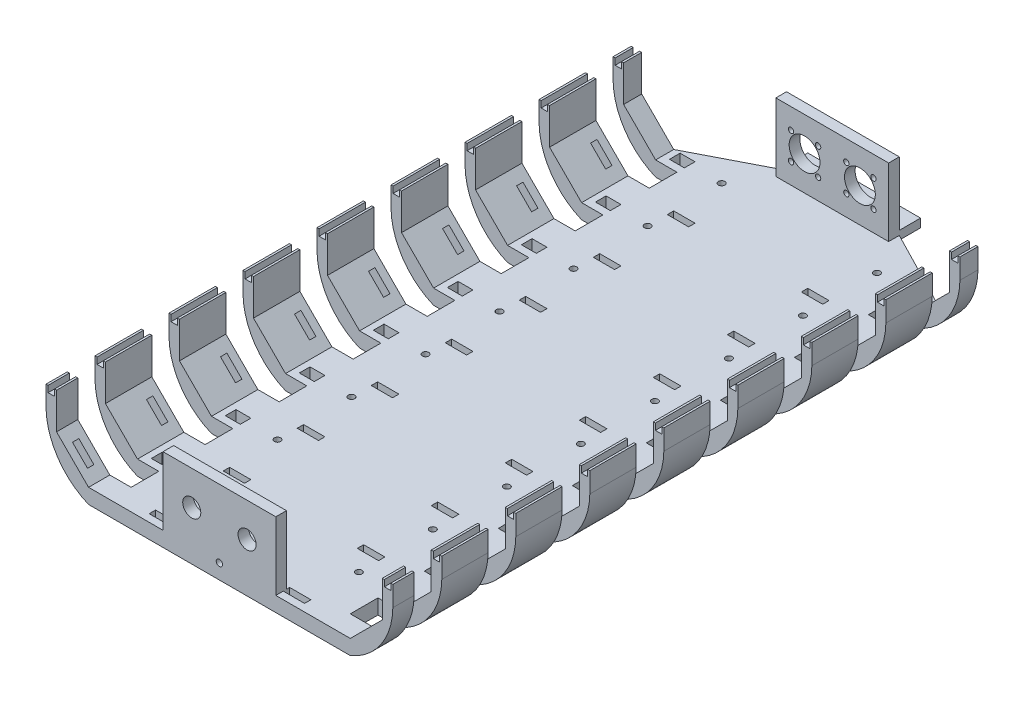
from build123d import *

# Parameters (mm, degrees)
BOSS_EXTRUDE1_DEPTH      = 7
SKETCH2_W                = 123
SKETCH2_H                = 5
BOSS_EXTRUDE2_DEPTH      = 32
SKETCH9_W                = 123
SKETCH9_H                = 7
BOSS_EXTRUDE4_DEPTH      = 5
SKETCH13_W               = 35
SKETCH13_H               = 32
CUT_EXTRUDE5_DEPTH       = 11
BOSS_EXTRUDE10_DEPTH     = 275
BOSS_EXTRUDE13_DEPTH     = 7
SKETCH18_W               = 53
SKETCH18_H               = 5
BOSS_EXTRUDE14_DEPTH     = 32
SKETCH3_R                = 4.25
CUT_EXTRUDE8_DEPTH       = 334
SKETCH19_R               = 7.25
SKETCH19_R_2             = 1.25
CUT_EXTRUDE9_DEPTH       = 334
CUT_EXTRUDE13_DEPTH      = 19
SKETCH32_R               = 1.5
SKETCH32_W               = 30
SKETCH32_H               = 13
SKETCH32_W_2             = 7
SKETCH32_H_2             = 5
CUT_EXTRUDE16_DEPTH      = 33
CUT_EXTRUDE16_DEPTH_BACK = 8
SKETCH33_W               = 10
SKETCH33_H               = 3
CUT_EXTRUDE18_DEPTH      = 4.5
SKETCH34_W               = 3
SKETCH34_H               = 10
CUT_EXTRUDE19_DEPTH      = 4.5
SKETCH35_W               = 3
SKETCH35_H               = 275
CUT_EXTRUDE20_DEPTH      = 3
SKETCH36_W               = 53
SKETCH36_H               = 4
BOSS_EXTRUDE15_DEPTH     = 10
SKETCH37_R               = 1.5
CUT_EXTRUDE21_DEPTH      = 10


with BuildPart() as part:
    # Sketch1 → Boss-Extrude1 (new body)
    with BuildSketch(Plane(origin=(0, 0, 0), x_dir=(1, 0, 0), z_dir=(0, 1, 0))):
        Polygon((-13, 135), (-36, 135), (-61.5, 135), (-61.5, -135), (-36, -135), (-13, -135), (13, -135), (36, -135), (61.5, -135), (61.5, 135), (36, 135), (13, 135), align=None)
    extrude(amount=BOSS_EXTRUDE1_DEPTH)

    # Sketch2 → Boss-Extrude2 (add)
    with BuildSketch(Plane(origin=(0, 7, 0), x_dir=(1, 0, 0), z_dir=(0, 1, 0))):
        with Locations((0, -132.5)):
            Rectangle(SKETCH2_W, SKETCH2_H)
    extrude(amount=BOSS_EXTRUDE2_DEPTH)

    # Sketch9 → Boss-Extrude4 (add)
    with BuildSketch(Plane(origin=(0, 0, -135), x_dir=(-1, 0, 0), z_dir=(0, 0, -1))):
        with Locations((0, 3.5)):
            Rectangle(SKETCH9_W, SKETCH9_H)
    extrude(amount=BOSS_EXTRUDE4_DEPTH)

    # Sketch13 → Cut-Extrude5 (cut)
    with BuildSketch(Plane.XY.offset(135)):
        with Locations((-44, 23)):
            Rectangle(SKETCH13_W, SKETCH13_H)
        with Locations((44, 23)):
            Rectangle(SKETCH13_W, SKETCH13_H)
    extrude(amount=-CUT_EXTRUDE5_DEPTH, mode=Mode.SUBTRACT)

    # Sketch14 → Boss-Extrude10 (add)
    with BuildSketch(Plane.XY.offset(135)):
        with BuildLine():
            Line((-76.55, 22.05), (-61.5, 7))
            Line((-61.5, 7), (-61.5, 0))
            ThreePointArc((-61.5, 0), (-75.904786932, 11.763703775), (-81.5, 29.5))
            Line((-81.5, 29.5), (-81.5, 39))
            Line((-81.5, 39), (-76.55, 39))
            Line((-76.55, 39), (-76.55, 22.05))
        make_face()
        with BuildLine():
            Line((81.5, 39), (76.55, 39))
            Line((76.55, 39), (76.55, 22.05))
            Line((76.55, 22.05), (61.5, 7))
            Line((61.5, 7), (61.5, 0))
            ThreePointArc((61.5, 0), (75.904786932, 11.763703775), (81.5, 29.5))
            Line((81.5, 29.5), (81.5, 39))
        make_face()
    extrude(amount=-BOSS_EXTRUDE10_DEPTH)

    # Sketch17 → Boss-Extrude13 (add)
    with BuildSketch(Plane(origin=(0, 7, 0), x_dir=(1, 0, 0), z_dir=(0, 1, 0))):
        Polygon((-61.5, 140), (-26.5, 226), (0, 226), (26.5, 226), (61.5, 140), align=None)
    extrude(amount=-BOSS_EXTRUDE13_DEPTH)

    # Sketch18 → Boss-Extrude14 (add)
    with BuildSketch(Plane(origin=(0, 7, 0), x_dir=(1, 0, 0), z_dir=(0, 1, 0))):
        with Locations((0, 155.5)):
            Rectangle(SKETCH18_W, SKETCH18_H)
    extrude(amount=BOSS_EXTRUDE14_DEPTH)

    # Sketch3 → Cut-Extrude8 (cut)
    with BuildSketch(Plane.XY.offset(135)):
        with Locations((-13, 23)):
            Circle(SKETCH3_R)
        with Locations((13, 23)):
            Circle(SKETCH3_R)
    extrude(amount=-CUT_EXTRUDE8_DEPTH, mode=Mode.SUBTRACT)

    # Sketch19 → Cut-Extrude9 (cut)
    with BuildSketch(Plane.XY.offset(-153)):
        with Locations((-13, 23)):
            Circle(SKETCH19_R)
        with Locations((-6.636038969, 16.636038969)):
            Circle(SKETCH19_R_2)
        with Locations((-6.636038969, 29.363961031)):
            Circle(SKETCH19_R_2)
        with Locations((-19.363961031, 29.363961031)):
            Circle(SKETCH19_R_2)
        with Locations((-19.363961031, 16.636038969)):
            Circle(SKETCH19_R_2)
        with Locations((13, 23)):
            Circle(SKETCH19_R)
        with Locations((19.363961031, 16.636038969)):
            Circle(SKETCH19_R_2)
        with Locations((6.636038969, 16.636038969)):
            Circle(SKETCH19_R_2)
        with Locations((6.636038969, 29.363961031)):
            Circle(SKETCH19_R_2)
        with Locations((19.363961031, 29.363961031)):
            Circle(SKETCH19_R_2)
    extrude(amount=-CUT_EXTRUDE9_DEPTH, mode=Mode.SUBTRACT)

    # Sketch29 → Cut-Extrude13 (cut)
    with BuildSketch(Plane(origin=(0, 7, 0), x_dir=(1, 0, 0), z_dir=(0, 1, 0))):
        Polygon((-61.5, 140), (-26.5, 158), (26.5, 158), (61.5, 140), (26.5, 226), (-26.5, 226), align=None)
    extrude(amount=-CUT_EXTRUDE13_DEPTH, mode=Mode.SUBTRACT)

    # Sketch32 → Cut-Extrude16 (cut, two sides)
    with BuildSketch(Plane(origin=(0, 7, 0), x_dir=(1, 0, 0), z_dir=(0, 1, 0))) as cut_extrude16_sk:
        with Locations((-36.5, 137.5)):
            Circle(SKETCH32_R)
        with Locations((-36.5, 102.714285714)):
            Circle(SKETCH32_R)
        with Locations((-36.5, 67.928571429)):
            Circle(SKETCH32_R)
        with Locations((-36.5, 33.142857143)):
            Circle(SKETCH32_R)
        with Locations((-36.5, -1.642857143)):
            Circle(SKETCH32_R)
        with Locations((-36.5, -36.428571429)):
            Circle(SKETCH32_R)
        with Locations((-36.5, -71.214285714)):
            Circle(SKETCH32_R)
        with Locations((-36.5, -106)):
            Circle(SKETCH32_R)
        with Locations((36.5, -106)):
            Circle(SKETCH32_R)
        with Locations((36.5, -71.214285714)):
            Circle(SKETCH32_R)
        with Locations((36.5, -36.428571429)):
            Circle(SKETCH32_R)
        with Locations((36.5, -1.642857143)):
            Circle(SKETCH32_R)
        with Locations((36.5, 33.142857143)):
            Circle(SKETCH32_R)
        with Locations((36.5, 67.928571429)):
            Circle(SKETCH32_R)
        with Locations((36.5, 102.714285714)):
            Circle(SKETCH32_R)
        with Locations((36.5, 137.5)):
            Circle(SKETCH32_R)
        with Locations((-66.5, 125)):
            Rectangle(SKETCH32_W, SKETCH32_H)
        with Locations((-55, 137.5)):
            Rectangle(SKETCH32_W_2, SKETCH32_H_2)
        with Locations((-66.5, 90.214285714)):
            Rectangle(SKETCH32_W, SKETCH32_H)
        with Locations((-55, 102.714285714)):
            Rectangle(SKETCH32_W_2, SKETCH32_H_2)
        with Locations((-66.5, 55.428571429)):
            Rectangle(SKETCH32_W, SKETCH32_H)
        with Locations((-55, 67.928571429)):
            Rectangle(SKETCH32_W_2, SKETCH32_H_2)
        with Locations((-66.5, 20.642857143)):
            Rectangle(SKETCH32_W, SKETCH32_H)
        with Locations((-55, 33.142857143)):
            Rectangle(SKETCH32_W_2, SKETCH32_H_2)
        with Locations((-66.5, -14.142857143)):
            Rectangle(SKETCH32_W, SKETCH32_H)
        with Locations((-55, -1.642857143)):
            Rectangle(SKETCH32_W_2, SKETCH32_H_2)
        with Locations((-66.5, -48.928571429)):
            Rectangle(SKETCH32_W, SKETCH32_H)
        with Locations((-55, -36.428571429)):
            Rectangle(SKETCH32_W_2, SKETCH32_H_2)
        with Locations((-66.5, -83.714285714)):
            Rectangle(SKETCH32_W, SKETCH32_H)
        with Locations((-55, -71.214285714)):
            Rectangle(SKETCH32_W_2, SKETCH32_H_2)
        with Locations((-66.5, -118.5)):
            Rectangle(SKETCH32_W, SKETCH32_H)
        with Locations((-55, -106)):
            Rectangle(SKETCH32_W_2, SKETCH32_H_2)
        with Locations((55, -106)):
            Rectangle(SKETCH32_W_2, SKETCH32_H_2)
        with Locations((66.5, -118.5)):
            Rectangle(SKETCH32_W, SKETCH32_H)
        with Locations((55, -71.214285714)):
            Rectangle(SKETCH32_W_2, SKETCH32_H_2)
        with Locations((66.5, -83.714285714)):
            Rectangle(SKETCH32_W, SKETCH32_H)
        with Locations((55, -36.428571429)):
            Rectangle(SKETCH32_W_2, SKETCH32_H_2)
        with Locations((66.5, -48.928571429)):
            Rectangle(SKETCH32_W, SKETCH32_H)
        with Locations((55, -1.642857143)):
            Rectangle(SKETCH32_W_2, SKETCH32_H_2)
        with Locations((66.5, -14.142857143)):
            Rectangle(SKETCH32_W, SKETCH32_H)
        with Locations((55, 33.142857143)):
            Rectangle(SKETCH32_W_2, SKETCH32_H_2)
        with Locations((66.5, 20.642857143)):
            Rectangle(SKETCH32_W, SKETCH32_H)
        with Locations((55, 67.928571429)):
            Rectangle(SKETCH32_W_2, SKETCH32_H_2)
        with Locations((66.5, 55.428571429)):
            Rectangle(SKETCH32_W, SKETCH32_H)
        with Locations((55, 102.714285714)):
            Rectangle(SKETCH32_W_2, SKETCH32_H_2)
        with Locations((66.5, 90.214285714)):
            Rectangle(SKETCH32_W, SKETCH32_H)
        with Locations((66.5, 125)):
            Rectangle(SKETCH32_W, SKETCH32_H)
        with Locations((55, 137.5)):
            Rectangle(SKETCH32_W_2, SKETCH32_H_2)
    extrude(amount=CUT_EXTRUDE16_DEPTH, mode=Mode.SUBTRACT)
    extrude(cut_extrude16_sk.sketch, amount=-CUT_EXTRUDE16_DEPTH_BACK, mode=Mode.SUBTRACT)

    # Sketch33 → Cut-Extrude18 (cut)
    with BuildSketch(Plane(origin=(0, 7, 0), x_dir=(1, 0, 0), z_dir=(0, 1, 0))):
        with Locations((-31.5, 113.5)):
            Rectangle(SKETCH33_W, SKETCH33_H)
        with Locations((-31.5, 78.714285714)):
            Rectangle(SKETCH33_W, SKETCH33_H)
        with Locations((-31.5, 43.928571429)):
            Rectangle(SKETCH33_W, SKETCH33_H)
        with Locations((-31.5, 9.142857143)):
            Rectangle(SKETCH33_W, SKETCH33_H)
        with Locations((-31.5, -25.642857143)):
            Rectangle(SKETCH33_W, SKETCH33_H)
        with Locations((-31.5, -60.428571429)):
            Rectangle(SKETCH33_W, SKETCH33_H)
        with Locations((-31.5, -95.214285714)):
            Rectangle(SKETCH33_W, SKETCH33_H)
        with Locations((-31.5, -130)):
            Rectangle(SKETCH33_W, SKETCH33_H)
        with Locations((31.5, -130)):
            Rectangle(SKETCH33_W, SKETCH33_H)
        with Locations((31.5, -95.214285714)):
            Rectangle(SKETCH33_W, SKETCH33_H)
        with Locations((31.5, -60.428571429)):
            Rectangle(SKETCH33_W, SKETCH33_H)
        with Locations((31.5, -25.642857143)):
            Rectangle(SKETCH33_W, SKETCH33_H)
        with Locations((31.5, 9.142857143)):
            Rectangle(SKETCH33_W, SKETCH33_H)
        with Locations((31.5, 43.928571429)):
            Rectangle(SKETCH33_W, SKETCH33_H)
        with Locations((31.5, 78.714285714)):
            Rectangle(SKETCH33_W, SKETCH33_H)
        with Locations((31.5, 113.5)):
            Rectangle(SKETCH33_W, SKETCH33_H)
    extrude(amount=-CUT_EXTRUDE18_DEPTH, mode=Mode.SUBTRACT)

    # Sketch34 → Cut-Extrude19 (cut)
    with BuildSketch(Plane(origin=(27.25, -27.25, 0), x_dir=(0, 0, 1), z_dir=(-0.707106781, 0.707106781, 0))):
        with Locations((-78.714285714, 59.078771568)):
            Rectangle(SKETCH34_W, SKETCH34_H)
        with Locations((-113.5, 59.078771568)):
            Rectangle(SKETCH34_W, SKETCH34_H)
        with Locations((-43.928571429, 59.078771568)):
            Rectangle(SKETCH34_W, SKETCH34_H)
        with Locations((-9.142857143, 59.078771568)):
            Rectangle(SKETCH34_W, SKETCH34_H)
        with Locations((25.642857143, 59.078771568)):
            Rectangle(SKETCH34_W, SKETCH34_H)
        with Locations((60.428571429, 59.078771568)):
            Rectangle(SKETCH34_W, SKETCH34_H)
        with Locations((95.214285714, 59.078771568)):
            Rectangle(SKETCH34_W, SKETCH34_H)
        with Locations((130, 59.078771568)):
            Rectangle(SKETCH34_W, SKETCH34_H)
    cut_extrude19 = extrude(amount=-CUT_EXTRUDE19_DEPTH, mode=Mode.SUBTRACT)

    # Mirror1: Cut-Extrude19 across plane
    add(cut_extrude19.mirror(Plane(origin=(0, 0, 0), x_dir=(0, 0, 1), z_dir=(1, 0, 0))), mode=Mode.SUBTRACT)

    # Sketch35 → Cut-Extrude20 (cut)
    with BuildSketch(Plane(origin=(0, 39, 0), x_dir=(1, 0, 0), z_dir=(0, 1, 0))):
        with Locations((-79.025, 2.5)):
            Rectangle(SKETCH35_W, SKETCH35_H)
        with Locations((79.025, 2.5)):
            Rectangle(SKETCH35_W, SKETCH35_H)
    extrude(amount=-CUT_EXTRUDE20_DEPTH, mode=Mode.SUBTRACT)

    # Sketch36 → Boss-Extrude15 (add)
    with BuildSketch(Plane(origin=(0, 0, -158), x_dir=(-1, 0, 0), z_dir=(0, 0, -1))):
        with Locations((0, 7.085276911)):
            Rectangle(SKETCH36_W, SKETCH36_H)
    extrude(amount=BOSS_EXTRUDE15_DEPTH)

    # Sketch37 → Cut-Extrude21 (cut)
    with BuildSketch(Plane.XY.offset(135)):
        with Locations((0, 7)):
            Circle(SKETCH37_R)
    extrude(amount=-CUT_EXTRUDE21_DEPTH, mode=Mode.SUBTRACT)


solid = part.part
